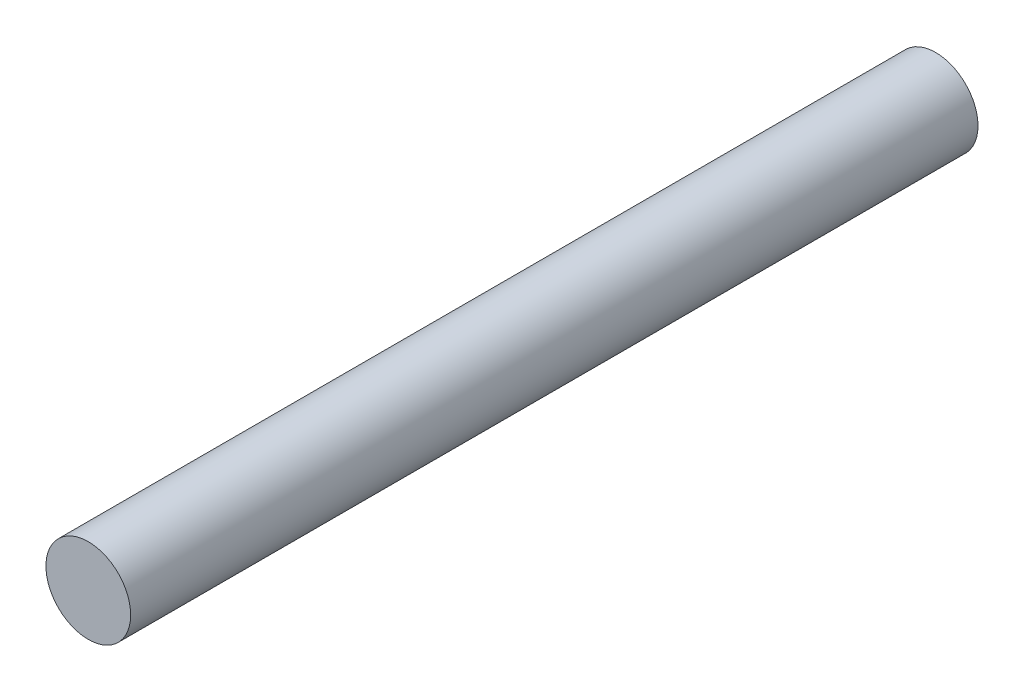
from build123d import *

# Parameters (mm, degrees)
ESQUISSE1_R        = 4
BOSS_EXTRU_1_DEPTH = 80


with BuildPart() as part:
    # Esquisse1 → Boss.-Extru.1 (new body)
    with BuildSketch(Plane.XY):
        Circle(ESQUISSE1_R)
    extrude(amount=BOSS_EXTRU_1_DEPTH)


solid = part.part
